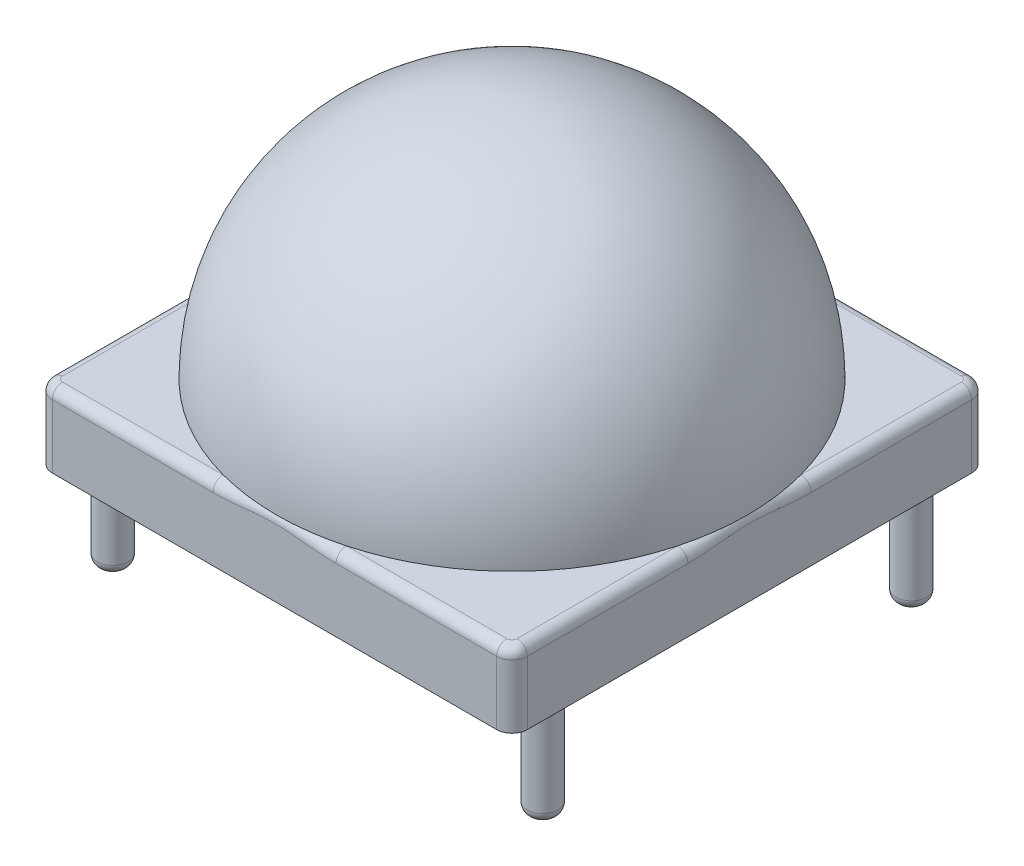
from build123d import *

# Parameters (mm, degrees)
BOSS_EXTRUDE1_DEPTH      = 2.6
BOSS_EXTRUDE1_DEPTH_BACK = 1
SKETCH1_W                = 23.2
SKETCH1_H                = 23.2
FILLET1_R                = 0.75
SHELL2_T                 = -2
SKETCH3_R                = 0.75
BOSS_EXTRUDE2_DEPTH      = 5
CUT_EXTRUDE4_DEPTH       = 12
CUT_EXTRUDE5_DEPTH       = 5
CIRPATTERN3_COUNT        = 5
CIRPATTERN3_ANGLE        = 288
CUT_EXTRUDE6_DEPTH       = 5
CIRPATTERN5_COUNT        = 5
CUT_EXTRUDE7_DEPTH       = 5
CIRPATTERN6_COUNT        = 5
CUT_EXTRUDE8_DEPTH       = 10.5
CIRPATTERN7_COUNT        = 10
FILLET2_R                = 0.5
FILLET3_R                = 0.5


with BuildPart() as part:
    # Sketch1 → Boss-Extrude1 (new, two sides: drawn at the far end of the back side and taken through both)
    with BuildSketch(Plane(origin=(0, 0, 0), x_dir=(1, 0, 0), z_dir=(0, 1, 0)).offset(-BOSS_EXTRUDE1_DEPTH_BACK)):
        Rectangle(SKETCH1_W, SKETCH1_H)
    extrude(amount=BOSS_EXTRUDE1_DEPTH + BOSS_EXTRUDE1_DEPTH_BACK)

    # Sketch2 → Revolve2 (revolve)
    with BuildSketch(Plane(origin=(0, 0, 0), x_dir=(0, 0, -1), z_dir=(1, 0, 0))):
        with BuildLine():
            Line((0, 2.6), (11.5, 2.6))
            ThreePointArc((11.5, 2.6), (8.131727984, 10.731727984), (0, 14.1))
            Line((0, 14.1), (0, 2.6))
        make_face()
    revolve(axis=Axis((0, -3.697621806, 0), (0, 1, 0)))

    # Fillet1
    fillet1_edges = [part.edges().sort_by_distance(p)[0] for p in [
        (-11.6, 0.8, -11.6),
        (-11.6, 0.8, 11.6),
        (11.6, 0.8, 11.6),
        (11.6, 0.8, -11.6),
    ]]
    fillet(fillet1_edges, radius=FILLET1_R)

    # Shell2
    shell2_openings = [part.faces().sort_by_distance(p)[0] for p in [
        (0, -1, 0),
    ]]
    offset(amount=SHELL2_T, openings=shell2_openings, kind=Kind.INTERSECTION)

    # Sketch3 → Boss-Extrude2 (add)
    with BuildSketch(Plane.XZ.offset(1)):
        with Locations((-10.5, 9)):
            Circle(SKETCH3_R)
        with Locations((10.5, 9)):
            Circle(SKETCH3_R)
        with Locations((10.5, -9)):
            Circle(SKETCH3_R)
        with Locations((-10.5, -9)):
            Circle(SKETCH3_R)
    extrude(amount=BOSS_EXTRUDE2_DEPTH)

    # Sketch7 → Cut-Extrude4 (cut)
    with BuildSketch(Plane(origin=(0, 0, 0), x_dir=(1, 0, 0), z_dir=(0, 1, 0))):
        Polygon((3.236067977, 1.051462224), (0, 3.402603233), (-3.236067977, 1.051462224), (-2, -2.752763841), (2, -2.752763841), align=None)
    extrude(amount=CUT_EXTRUDE4_DEPTH, mode=Mode.SUBTRACT)

    # Sketch8 → Cut-Extrude5 (cut)
    with BuildSketch(Plane(origin=(5.963531209, 9.733998156, 1.937668749), x_dir=(0.30901699437494734, 0, -0.9510565162951535), z_dir=(0.5150380749100523, 0.8406729998681941, 0.16734601484815498))):
        Polygon((4, 0.720241107), (2, 4.184342722), (-2, 4.184342722), (-4, 0.720241107), (-2, -2.743860509), (2, -2.743860509), align=None)
    cut_extrude5 = extrude(amount=-CUT_EXTRUDE5_DEPTH, mode=Mode.SUBTRACT)

    # CirPattern3: Cut-Extrude5 ×5 about axis
    cirpattern3_axis = Axis((0, -50, 0), (0, 1, 0))
    for i in range(1, CIRPATTERN3_COUNT):
        add(cut_extrude5.rotate(cirpattern3_axis, i * CIRPATTERN3_ANGLE / (CIRPATTERN3_COUNT - 1)), mode=Mode.SUBTRACT)

    # Sketch9 → Cut-Extrude6 (cut)
    with BuildSketch(Plane(origin=(-9.401291455, 4.751705803, -3.054664764), x_dir=(0.3090169943749441, 1.3918437178036583e-15, -0.9510565162951546), z_dir=(-0.8571673007021156, 0.4332390775224757, -0.27851053896490774))):
        Polygon((3.448229388, 0.019241973), (0, 2.010078139), (-3.448229388, 0.019241973), (-3.448229388, -3.962430358), (0, -5.953266523), (3.448229388, -3.962430358), align=None)
    cut_extrude6 = extrude(amount=-CUT_EXTRUDE6_DEPTH, mode=Mode.SUBTRACT)

    # CirPattern5: Cut-Extrude6 ×5 about axis
    cirpattern5_axis = Axis((0, -50, 0), (0, 1, 0))
    for i in range(1, CIRPATTERN5_COUNT):
        add(cut_extrude6.rotate(cirpattern5_axis, i * 360 / CIRPATTERN5_COUNT), mode=Mode.SUBTRACT)

    # Sketch10 → Cut-Extrude7 (cut)
    with BuildSketch(Plane(origin=(-9.732336979, 4.370737336, 3.162227975), x_dir=(-0.309016994374968, 1.0328810263435713e-15, -0.951056516295147), z_dir=(-0.8746197071393985, 0.39278674971179933, 0.28418116956306816))):
        Polygon((1.998985438, -4.216199894), (3.234426381, -0.413903641), (0, 1.936044679), (-3.234426381, -0.413903641), (-1.998985438, -4.216199894), align=None)
    cut_extrude7 = extrude(amount=-CUT_EXTRUDE7_DEPTH, mode=Mode.SUBTRACT)

    # CirPattern6: Cut-Extrude7 ×5 about axis
    cirpattern6_axis = Axis((0, -50, 0), (0, 1, 0))
    for i in range(1, CIRPATTERN6_COUNT):
        add(cut_extrude7.rotate(cirpattern6_axis, i * 360 / CIRPATTERN6_COUNT), mode=Mode.SUBTRACT)

    # Sketch11 → Cut-Extrude8 (cut)
    with BuildSketch(Plane(origin=(0, 0, 0), x_dir=(0, 0, -1), z_dir=(1, 0, 0))):
        Polygon((-3.280028681, 2.6), (3.333680227, 2.6), (3.323770482, 2.940064515), (-0.035866983, 4.751375369), (-3.284326929, 2.747499403), align=None)
    cut_extrude8 = extrude(amount=CUT_EXTRUDE8_DEPTH, mode=Mode.SUBTRACT)

    # CirPattern7: Cut-Extrude8 ×10 about axis
    cirpattern7_axis = Axis((0, 50, 0), (0, -1, 0))
    for i in range(1, CIRPATTERN7_COUNT):
        add(cut_extrude8.rotate(cirpattern7_axis, i * 360 / CIRPATTERN7_COUNT), mode=Mode.SUBTRACT)

    # Fillet2
    fillet2_edges = [part.edges().sort_by_distance(p)[0] for p in [
        (11.380330086, 2.6, -11.380330086),
        (11.6, 2.6, 0),
        (-11.6, 2.6, 0),
        (-11.380330086, 2.6, -11.380330086),
        (0, 2.6, -11.6),
        (11.380330086, 2.6, 11.380330086),
        (0, 2.6, 11.6),
        (-11.380330086, 2.6, 11.380330086),
    ]]
    fillet(fillet2_edges, radius=FILLET2_R)

    # Fillet3
    fillet3_edges = [part.edges().sort_by_distance(p)[0] for p in [
        (-11.25, -6, -9),
        (9.75, -6, -9),
        (9.75, -6, 9),
        (-11.25, -6, 9),
    ]]
    fillet(fillet3_edges, radius=FILLET3_R)


solid = part.part
